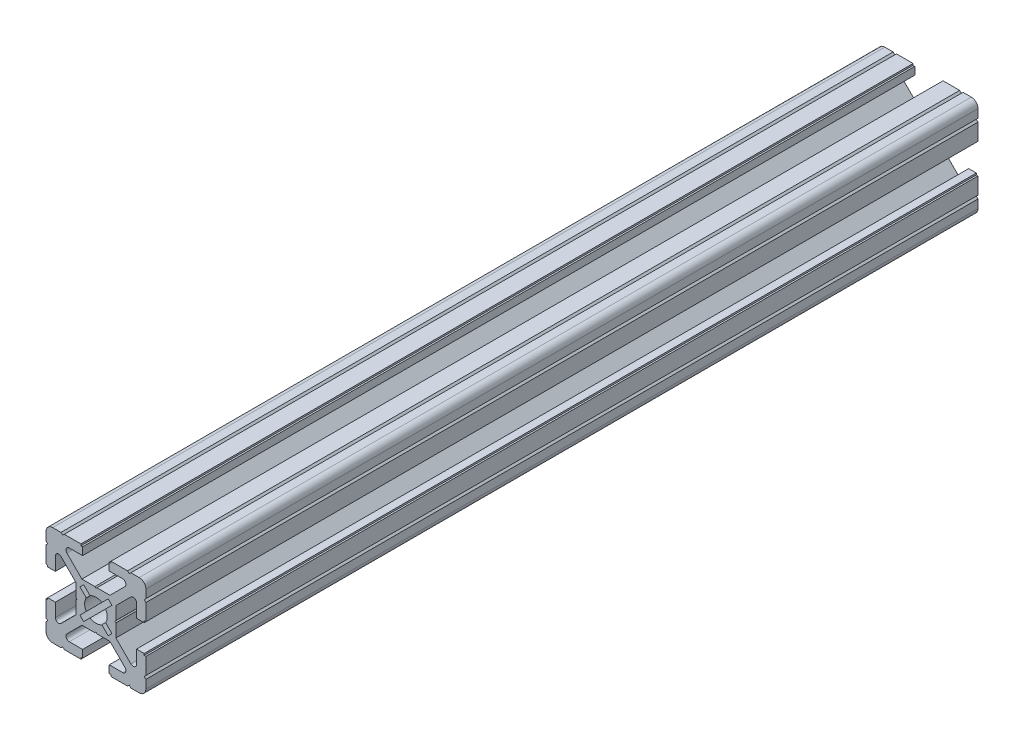
from build123d import *

# Parameters (mm, degrees)
BOSS_EXTRUDE1_DEPTH = 250


with BuildPart() as part:
    # Sketch1 → Boss-Extrude1 (new body)
    with BuildSketch(Plane(origin=(0, 0, -150), x_dir=(-1, 0, 0), z_dir=(0, 0, -1))):
        with BuildLine():
            Line((-14.999999999, 12.999999999), (-14.999999999, 10.499999999))
            Line((-14.999999999, 10.499999999), (-14.499999999, 9.999999999))
            Line((-14.499999999, 9.999999999), (-14.999999999, 9.5))
            Line((-14.999999999, 9.5), (-14.999999999, 4.5))
            Line((-14.999999999, 4.5), (-14.5, 4.5))
            Line((-14.5, 4.5), (-14.5, 4))
            Line((-14.5, 4), (-12.200000005, 4))
            Line((-12.200000005, 4), (-12.200000005, 7.999999995))
            ThreePointArc((-12.200000005, 7.999999995), (-11.582683434, 8.923879532), (-10.492893215, 8.70710678))
            Line((-10.492893215, 8.70710678), (-6, 4.214213564))
            Line((-6, 4.214213564), (-6, 0.312520903))
            Line((-6, 0.312520903), (-5.7, 0))
            Line((-5.7, 0), (-6, -0.312520901))
            Line((-6, -0.312520901), (-6, -4.214213564))
            Line((-6, -4.214213564), (-10.492893215, -8.70710678))
            ThreePointArc((-10.492893215, -8.70710678), (-11.582683434, -8.923879532), (-12.200000005, -7.999999995))
            Line((-12.200000005, -7.999999995), (-12.200000005, -4))
            Line((-12.200000005, -4), (-14.5, -4))
            Line((-14.5, -4), (-14.5, -4.5))
            Line((-14.5, -4.5), (-14.999999999, -4.5))
            Line((-14.999999999, -4.5), (-14.999999999, -9.500000003))
            Line((-14.999999999, -9.500000003), (-14.499999999, -10.000000002))
            Line((-14.499999999, -10.000000002), (-14.999999999, -10.500000001))
            Line((-14.999999999, -10.500000001), (-14.999999999, -13))
            ThreePointArc((-14.999999999, -13), (-14.414213561, -14.414213562), (-12.999999999, -15))
            Line((-12.999999999, -15), (-10.5, -15))
            Line((-10.5, -15), (-10.000000001, -14.500000001))
            Line((-10.000000001, -14.500000001), (-9.500000001, -15))
            Line((-9.500000001, -15), (-4.5, -15))
            Line((-4.5, -15), (-4.5, -14.5))
            Line((-4.5, -14.5), (-4, -14.5))
            Line((-4, -14.5), (-4, -12.200000005))
            Line((-4, -12.200000005), (-7.999999995, -12.200000005))
            ThreePointArc((-7.999999995, -12.200000005), (-8.923879532, -11.582683434), (-8.70710678, -10.492893215))
            Line((-8.70710678, -10.492893215), (-4.214213564, -6))
            Line((-4.214213564, -6), (-0.312520903, -6))
            Line((-0.312520903, -6), (0, -5.7))
            Line((0, -5.7), (0.312520901, -6))
            Line((0.312520901, -6), (4.214213564, -6))
            Line((4.214213564, -6), (8.70710678, -10.492893215))
            ThreePointArc((8.70710678, -10.492893215), (8.923879532, -11.582683434), (7.999999995, -12.200000005))
            Line((7.999999995, -12.200000005), (4, -12.200000005))
            Line((4, -12.200000005), (4, -14.5))
            Line((4, -14.5), (4.5, -14.5))
            Line((4.5, -14.5), (4.5, -15))
            Line((4.5, -15), (9.500000001, -15))
            Line((9.500000001, -15), (9.989897949, -14.5))
            Line((9.989897949, -14.5), (10.489897949, -15))
            Line((10.489897949, -15), (13, -15))
            ThreePointArc((13, -15), (14.414213562, -14.414213562), (15, -13))
            Line((15, -13), (15, -10.5))
            Line((15, -10.5), (14.500000001, -10.000000001))
            Line((14.500000001, -10.000000001), (15, -9.500000001))
            Line((15, -9.500000001), (15, -4.5))
            Line((15, -4.5), (14.5, -4.5))
            Line((14.5, -4.5), (14.5, -4))
            Line((14.5, -4), (12.200000005, -4))
            Line((12.200000005, -4), (12.200000005, -7.999999995))
            ThreePointArc((12.200000005, -7.999999995), (11.582683434, -8.923879532), (10.492893215, -8.70710678))
            Line((10.492893215, -8.70710678), (6, -4.214213564))
            Line((6, -4.214213564), (6, -0.312520903))
            Line((6, -0.312520903), (5.7, 0))
            Line((5.7, 0), (6, 0.312520901))
            Line((6, 0.312520901), (6, 4.214213564))
            Line((6, 4.214213564), (10.492893215, 8.707106779))
            ThreePointArc((10.492893215, 8.707106779), (11.582683434, 8.923879532), (12.200000005, 7.999999994))
            Line((12.200000005, 7.999999994), (12.200000005, 4))
            Line((12.200000005, 4), (14.5, 4))
            Line((14.5, 4), (14.5, 4.5))
            Line((14.5, 4.5), (15, 4.5))
            Line((15, 4.5), (15, 9.500000001))
            Line((15, 9.500000001), (14.500000001, 10.000000001))
            Line((14.500000001, 10.000000001), (15, 10.5))
            Line((15, 10.5), (15, 12.999999999))
            ThreePointArc((15, 12.999999999), (14.414213562, 14.414213561), (13, 14.999999999))
            Line((13, 14.999999999), (10.500000001, 14.999999999))
            Line((10.500000001, 14.999999999), (10.000000002, 14.499999999))
            Line((10.000000002, 14.499999999), (9.500000003, 14.999999999))
            Line((9.500000003, 14.999999999), (4.5, 14.999999999))
            Line((4.5, 14.999999999), (4.5, 14.5))
            Line((4.5, 14.5), (4, 14.5))
            Line((4, 14.5), (4, 12.200000005))
            Line((4, 12.200000005), (7.999999995, 12.200000005))
            ThreePointArc((7.999999995, 12.200000005), (8.923879532, 11.582683434), (8.70710678, 10.492893215))
            Line((8.70710678, 10.492893215), (4.214213564, 6))
            Line((4.214213564, 6), (0.312520903, 6))
            Line((0.312520903, 6), (0, 5.7))
            Line((0, 5.7), (-0.312520901, 6))
            Line((-0.312520901, 6), (-4.214213564, 6))
            Line((-4.214213564, 6), (-8.707106779, 10.492893215))
            ThreePointArc((-8.707106779, 10.492893215), (-8.923879532, 11.582683434), (-7.999999994, 12.200000005))
            Line((-7.999999994, 12.200000005), (-4, 12.200000005))
            Line((-4, 12.200000005), (-4, 14.5))
            Line((-4, 14.5), (-4.5, 14.5))
            Line((-4.5, 14.5), (-4.5, 14.999999999))
            Line((-4.5, 14.999999999), (-9.5, 14.999999999))
            Line((-9.5, 14.999999999), (-9.999999999, 14.499999999))
            Line((-9.999999999, 14.499999999), (-10.499999999, 14.999999999))
            Line((-10.499999999, 14.999999999), (-12.999999999, 14.999999999))
            ThreePointArc((-12.999999999, 14.999999999), (-14.414213561, 14.414213561), (-14.999999999, 12.999999999))
        make_face()
        with BuildLine():
            Line((4.808326112, 3.676955262), (2.902349714, 1.770978864))
            ThreePointArc((2.902349714, 1.770978864), (3.4, 0), (2.902349714, -1.770978864))
            Line((2.902349714, -1.770978864), (4.808326112, -3.676955262))
            Line((4.808326112, -3.676955262), (3.676955262, -4.808326112))
            Line((3.676955262, -4.808326112), (1.770978864, -2.902349714))
            ThreePointArc((1.770978864, -2.902349714), (0, -3.4), (-1.770978864, -2.902349714))
            Line((-1.770978864, -2.902349714), (-3.676955262, -4.808326112))
            Line((-3.676955262, -4.808326112), (-4.808326112, -3.676955262))
            Line((-4.808326112, -3.676955262), (-2.902349714, -1.770978864))
            ThreePointArc((-2.902349714, -1.770978864), (-3.4, 0), (-2.902349714, 1.770978864))
            Line((-2.902349714, 1.770978864), (-4.808326112, 3.676955262))
            Line((-4.808326112, 3.676955262), (-3.676955262, 4.808326112))
            Line((-3.676955262, 4.808326112), (-1.770978864, 2.902349714))
            ThreePointArc((-1.770978864, 2.902349714), (0, 3.4), (1.770978864, 2.902349714))
            Line((1.770978864, 2.902349714), (3.676955262, 4.808326112))
            Line((3.676955262, 4.808326112), (4.808326112, 3.676955262))
        make_face(mode=Mode.SUBTRACT)
    extrude(amount=-BOSS_EXTRUDE1_DEPTH)


solid = part.part
